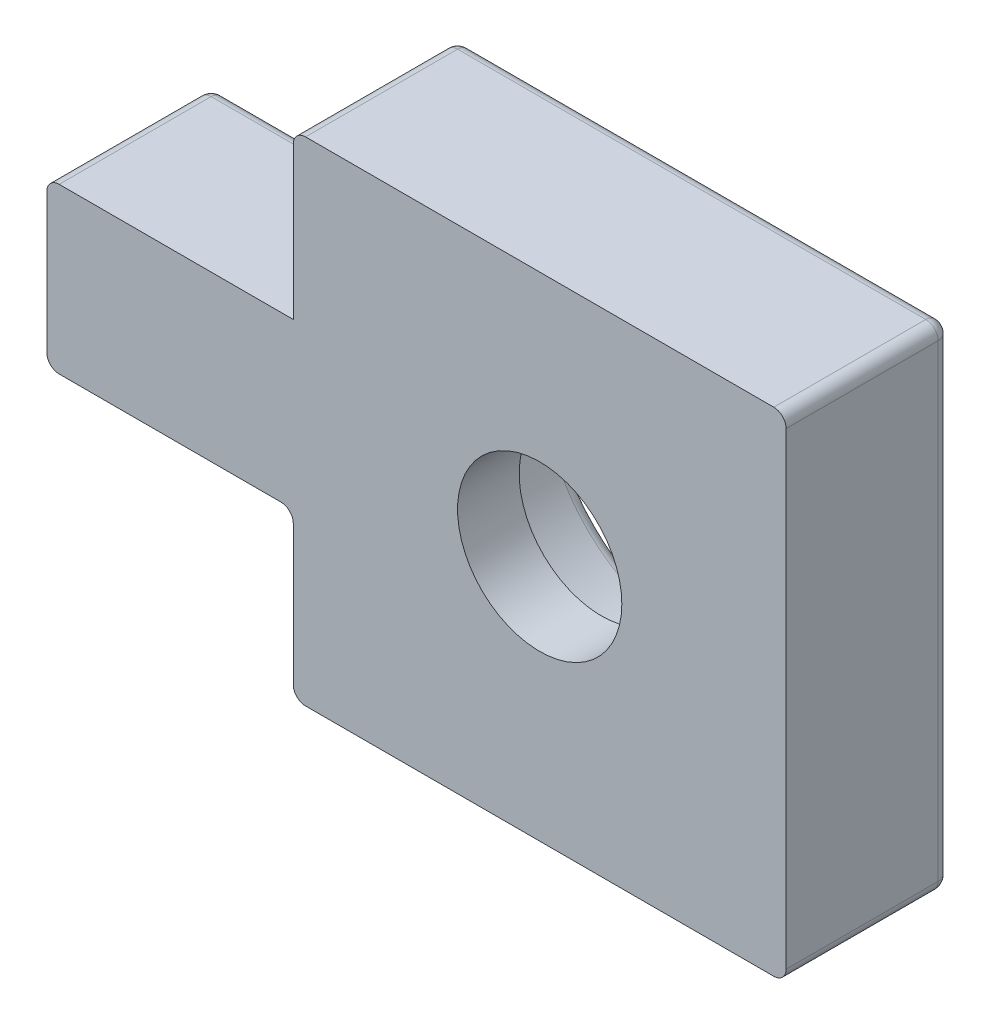
from build123d import *

# Parameters (mm, degrees)
ESQUISSE1_W             = 12
ESQUISSE1_H             = 12
BOSS_EXTRU_1_DEPTH      = 4
ESQUISSE2_R             = 2
ENL_V_MAT_EXTRU_2_DEPTH = 4
ESQUISSE3_R             = 3.6
ENL_V_MAT_EXTRU_3_DEPTH = 2.5
ESQUISSE4_W             = 6
ESQUISSE4_H             = 4
BOSS_EXTRU_2_DEPTH      = 4
ESQUISSE5_R             = 1.25
BOSS_EXTRU_3_DEPTH      = 4
BOSS_EXTRU_3_TAPER      = 2
CHANFREIN1_SIZE2        = 0.5
CHANFREIN1_SIZE         = 0.518407978
CONG_1_R                = 0.3


with BuildPart() as part:
    # Esquisse1 → Boss.-Extru.1 (new body)
    with BuildSketch(Plane.XY):
        with Locations((6, 6)):
            Rectangle(ESQUISSE1_W, ESQUISSE1_H)
    extrude(amount=BOSS_EXTRU_1_DEPTH)

    # Esquisse2 → Enlèv. mat.-Extru.2 (cut)
    with BuildSketch(Plane.XY):
        with Locations((6, 6)):
            Circle(ESQUISSE2_R)
    extrude(amount=ENL_V_MAT_EXTRU_2_DEPTH, mode=Mode.SUBTRACT)

    # Esquisse3 → Enlèv. mat.-Extru.3 (cut)
    with BuildSketch(Plane.XY):
        with Locations((6, 6)):
            Circle(ESQUISSE3_R)
    extrude(amount=ENL_V_MAT_EXTRU_3_DEPTH, mode=Mode.SUBTRACT)

    # Esquisse4 → Boss.-Extru.2 (add)
    with BuildSketch(Plane.XY):
        with Locations((-3, 6)):
            Rectangle(ESQUISSE4_W, ESQUISSE4_H)
    extrude(amount=BOSS_EXTRU_2_DEPTH)

    # Esquisse5 → Boss.-Extru.3 (add)
    with BuildSketch(Plane.XY):
        with Locations((-4, 6)):
            Circle(ESQUISSE5_R)
    extrude(amount=-BOSS_EXTRU_3_DEPTH, taper=BOSS_EXTRU_3_TAPER)

    # Chanfrein1
    chanfrein1_edges = [part.edges().sort_by_distance(p)[0] for p in [
        (-5.110316922, 6, -4),
    ]]
    chamfer(chanfrein1_edges, length=CHANFREIN1_SIZE, length2=CHANFREIN1_SIZE2)

    # Congé1
    cong_1_edges = [part.edges().sort_by_distance(p)[0] for p in [
        (2.4, 6, 0),
        (0, 2, 0),
        (0, 4, 2),
        (-3, 8, 0),
        (-6, 6, 0),
        (-6, 8, 2),
        (-3, 4, 0),
        (-6, 4, 2),
        (-5.25, 6, 0),
        (6, 12, 0),
        (12, 6, 0),
        (6, 0, 0),
        (0, 10, 0),
        (0, 12, 2),
        (12, 12, 2),
        (12, 0, 2),
        (0, 0, 2),
    ]]
    fillet(cong_1_edges, radius=CONG_1_R)


solid = part.part
